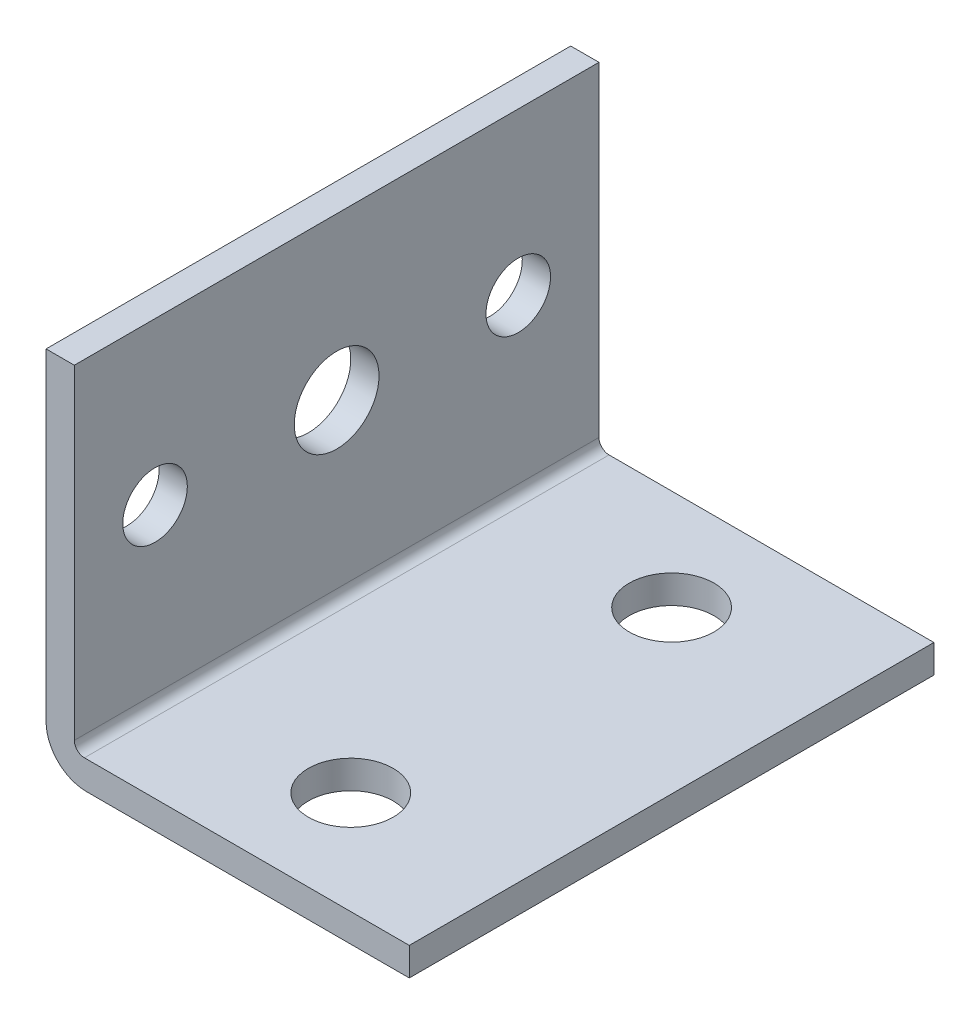
from build123d import *

# Parameters (mm, degrees)
BOSS_EXTRUDE1_DEPTH = 66.04
FILLET1_R           = 1.27
FILLET3_R           = 5.08
SKETCH2_R           = 5.334
SKETCH2_R_2         = 4.064
CUT_EXTRUDE1_DEPTH  = 66.04
SKETCH3_R           = 5.334
CUT_EXTRUDE2_DEPTH  = 66.04


with BuildPart() as part:
    # Sketch1 → Boss-Extrude1 (new body)
    with BuildSketch(Plane.XY):
        Polygon((-20.634190635, 26.453063941), (-20.634190635, -19.266936059), (25.085809365, -19.266936059), (25.085809365, -15.710936059), (-17.078190635, -15.710936059), (-17.078190635, 26.453063941), align=None)
    extrude(amount=-BOSS_EXTRUDE1_DEPTH)

    # Fillet1
    fillet1_edges = [part.edges().sort_by_distance(p)[0] for p in [
        (-17.078190635, -15.710936059, -33.02),
    ]]
    fillet(fillet1_edges, radius=FILLET1_R)

    # Fillet3
    fillet3_edges = [part.edges().sort_by_distance(p)[0] for p in [
        (-20.634190635, -19.266936059, -33.02),
    ]]
    fillet(fillet3_edges, radius=FILLET3_R)

    # Sketch2 → Cut-Extrude1 (cut)
    with BuildSketch(Plane.ZY.offset(20.634190635)):
        with Locations(Location((-33.02, 6.133063941, 0), (0, 0, 270))):  # turned: the seam where the file's is
            Circle(SKETCH2_R)
        with Locations(Location((-55.88, 6.133063941, 0), (0, 0, 270))):  # turned: the seam where the file's is
            Circle(SKETCH2_R_2)
        with Locations(Location((-10.16, 6.133063941, 0), (0, 0, 270))):  # turned: the seam where the file's is
            Circle(SKETCH2_R_2)
    extrude(amount=-CUT_EXTRUDE1_DEPTH, mode=Mode.SUBTRACT)

    # Sketch3 → Cut-Extrude2 (cut)
    with BuildSketch(Plane(origin=(0, -19.266936059, 0), x_dir=(-1, 0, 0), z_dir=(0, -1, 0))):
        with Locations(Location((-4.765809365, 12.954, 0), (0, 0, 90))):  # turned: the seam where the file's is
            Circle(SKETCH3_R)
        with Locations(Location((-4.765809365, 53.34, 0), (0, 0, 90))):  # turned: the seam where the file's is
            Circle(SKETCH3_R)
    extrude(amount=-CUT_EXTRUDE2_DEPTH, mode=Mode.SUBTRACT)


solid = part.part
